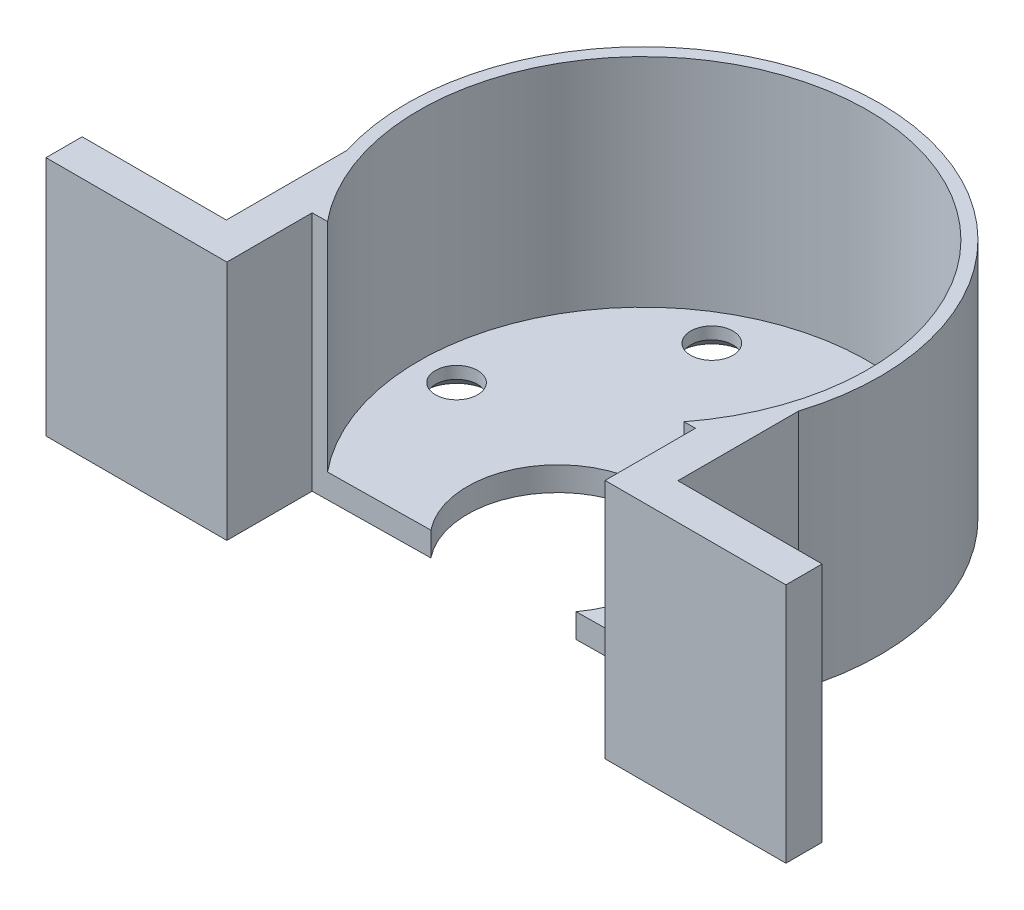
from build123d import *

# Parameters (mm, degrees)
BOSS_EXTRUDE2_DEPTH                                 = 20
SKETCH3_R                                           = 18.625
CUT_EXTRUDE1_DEPTH                                  = 18
SKETCH5_R                                           = 7.5
CUT_EXTRUDE2_DEPTH                                  = 2
CSK_FOR_M3_COUNTERSUNK_FLAT_HEAD_SCREW2_D           = 3.5
CSK_FOR_M3_COUNTERSUNK_FLAT_HEAD_SCREW2_CSINK_D     = 5.5
CSK_FOR_M3_COUNTERSUNK_FLAT_HEAD_SCREW2_CSINK_ANGLE = 90


with BuildPart() as part:
    # Sketch1 → Boss-Extrude2 (new body)
    with BuildSketch(Plane(origin=(0, 0, 0), x_dir=(1, 0, 0), z_dir=(0, 1, 0))):
        with BuildLine():
            Line((-18.727852322, -5.86584797), (-18.727852322, -15.86584797))
            Line((-18.727852322, -15.86584797), (-30.687012052, -15.86584797))
            Line((-30.687012052, -15.86584797), (-30.687012052, -18.86584797))
            Line((-30.687012052, -18.86584797), (-15.687012052, -18.86584797))
            Line((-15.687012052, -18.86584797), (-15.687012052, -11.792297397))
            Line((-15.687012052, -11.792297397), (15.687012052, -11.366724546))
            Line((15.687012052, -11.366724546), (15.687012052, -18.86584797))
            Line((15.687012052, -18.86584797), (30.687012052, -18.86584797))
            Line((30.687012052, -18.86584797), (30.687012052, -15.86584797))
            Line((30.687012052, -15.86584797), (18.727852322, -15.86584797))
            Line((18.727852322, -15.86584797), (18.727852322, -5.86584797))
            ThreePointArc((18.727852322, -5.86584797), (0, 19.625), (-18.727852322, -5.86584797))
        make_face()
    extrude(amount=BOSS_EXTRUDE2_DEPTH)

    # Sketch3 → Cut-Extrude1 (cut)
    with BuildSketch(Plane(origin=(0, 20, 0), x_dir=(1, 0, 0), z_dir=(0, 1, 0))):
        Circle(SKETCH3_R)
    extrude(amount=-CUT_EXTRUDE1_DEPTH, mode=Mode.SUBTRACT)

    # Sketch5 → Cut-Extrude2 (cut)
    with BuildSketch(Plane(origin=(0, 2, 0), x_dir=(1, 0, 0), z_dir=(0, 1, 0))):
        with Locations((-0.094951478, -7)):
            Circle(SKETCH5_R)
    extrude(amount=-CUT_EXTRUDE2_DEPTH, mode=Mode.SUBTRACT)

    # CSK for M3 Countersunk Flat Head Screw2 (through all)
    with Locations(Plane(origin=(7.75, 0, -13.423393759), x_dir=(0, 0, -1), z_dir=(0, -1, 0))):
        with Locations((0, 0), (0, -15.5), (-13.423393759, -23.25), (-13.423393759, 7.75)):
            CounterSinkHole(CSK_FOR_M3_COUNTERSUNK_FLAT_HEAD_SCREW2_D / 2, CSK_FOR_M3_COUNTERSUNK_FLAT_HEAD_SCREW2_CSINK_D / 2, counter_sink_angle=CSK_FOR_M3_COUNTERSUNK_FLAT_HEAD_SCREW2_CSINK_ANGLE)


solid = part.part
